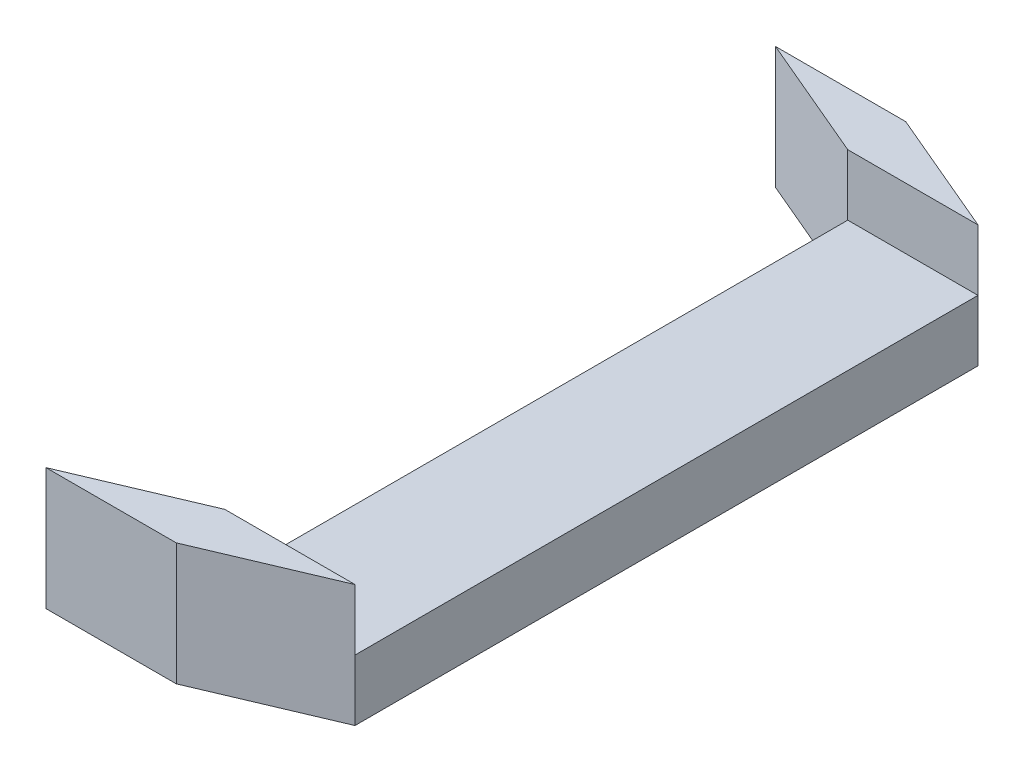
from build123d import *

# Parameters (mm, degrees)
SKETCH1_W           = 6.4
SKETCH1_H           = 30.61
BOSS_EXTRUDE1_DEPTH = 3
BOSS_EXTRUDE2_DEPTH = 6


with BuildPart() as part:
    # Sketch1 → Boss-Extrude1 (new body)
    with BuildSketch(Plane(origin=(0, 0, 0), x_dir=(1, 0, 0), z_dir=(0, 1, 0))):
        Rectangle(SKETCH1_W, SKETCH1_H)
    extrude(amount=BOSS_EXTRUDE1_DEPTH)

    # Sketch1_3 → Boss-Extrude2 (add)
    with BuildSketch(Plane(origin=(0, 0, 0), x_dir=(1, 0, 0), z_dir=(0, 1, 0))):
        Polygon((-3.2, 15.305), (3.2, 15.305), (-2.966154938, 17.922377484), (-9.366154938, 17.922377484), align=None)
        Polygon((-2.966154938, -17.922377484), (3.2, -15.305), (-3.2, -15.305), (-9.366154938, -17.922377484), align=None)
    extrude(amount=BOSS_EXTRUDE2_DEPTH)


solid = part.part
